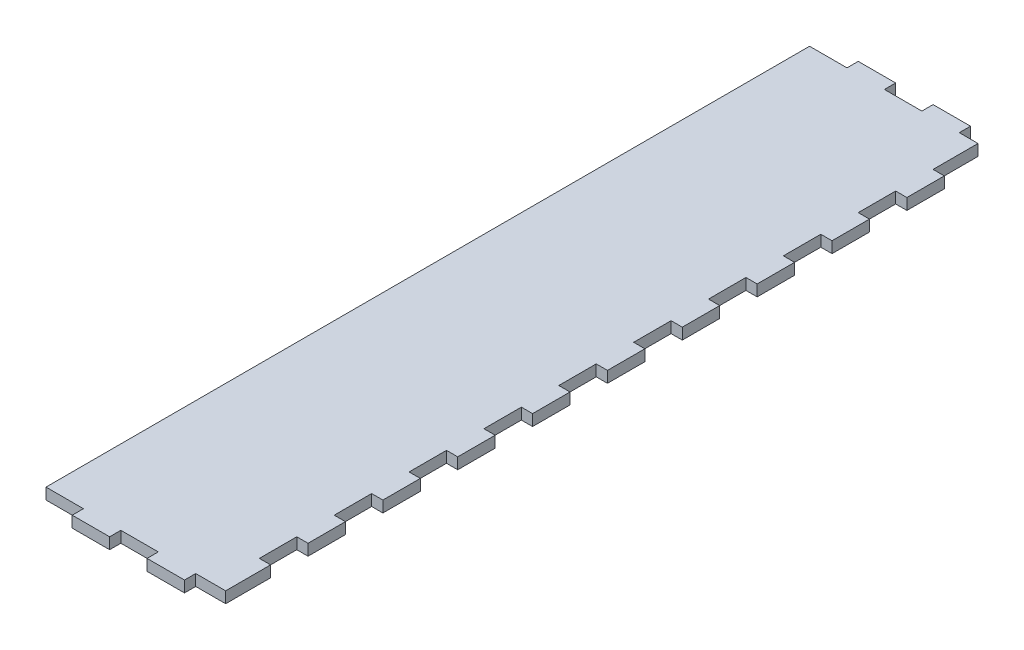
from build123d import *

# Parameters (mm, degrees)
SKETCH1_W           = 45
SKETCH1_H           = 204
BOSS_EXTRUDE1_DEPTH = 3
SKETCH2_W           = 10
SKETCH2_H           = 3
BOSS_EXTRUDE2_DEPTH = 3
LPATTERN1_COUNT     = 2
LPATTERN1_PITCH     = 20
SKETCH3_W           = 10
SKETCH3_H           = 3
BOSS_EXTRUDE3_DEPTH = 3
LPATTERN2_COUNT     = 2
LPATTERN2_PITCH     = 20
SKETCH4_W           = 12
SKETCH4_H           = 3
SKETCH4_W_2         = 10
BOSS_EXTRUDE4_DEPTH = 3


with BuildPart() as part:
    # Sketch1 → Boss-Extrude1 (new body)
    with BuildSketch(Plane(origin=(0, 0, 0), x_dir=(1, 0, 0), z_dir=(0, 1, 0))):
        with Locations((22.5, 102)):
            Rectangle(SKETCH1_W, SKETCH1_H)
    extrude(amount=BOSS_EXTRUDE1_DEPTH)

    # Sketch2 → Boss-Extrude2 (add)
    with BuildSketch(Plane.XY):
        with Locations((35, 1.5)):
            Rectangle(SKETCH2_W, SKETCH2_H)
    boss_extrude2 = extrude(amount=BOSS_EXTRUDE2_DEPTH)

    # LPattern1: Boss-Extrude2 ×2
    with Locations(*[(-i * LPATTERN1_PITCH, 0, 0) for i in range(1, LPATTERN1_COUNT)]):
        add(boss_extrude2)

    # Sketch3 → Boss-Extrude3 (add)
    with BuildSketch(Plane(origin=(0, 0, -204), x_dir=(-1, 0, 0), z_dir=(0, 0, -1))):
        with Locations((-35, 1.5)):
            Rectangle(SKETCH3_W, SKETCH3_H)
    boss_extrude3 = extrude(amount=BOSS_EXTRUDE3_DEPTH)

    # LPattern2: Boss-Extrude3 ×2
    with Locations(*[(-i * LPATTERN2_PITCH, 0, 0) for i in range(1, LPATTERN2_COUNT)]):
        add(boss_extrude3)

    # Sketch4 → Boss-Extrude4 (add)
    with BuildSketch(Plane(origin=(45, 0, 0), x_dir=(0, 0, -1), z_dir=(1, 0, 0))):
        with Locations((6, 1.5)):
            Rectangle(SKETCH4_W, SKETCH4_H)
        with Locations((27, 1.5)):
            Rectangle(SKETCH4_W_2, SKETCH4_H)
        with Locations((47, 1.5)):
            Rectangle(SKETCH4_W_2, SKETCH4_H)
        with Locations((67, 1.5)):
            Rectangle(SKETCH4_W_2, SKETCH4_H)
        with Locations((87, 1.5)):
            Rectangle(SKETCH4_W_2, SKETCH4_H)
        with Locations((107, 1.5)):
            Rectangle(SKETCH4_W_2, SKETCH4_H)
        with Locations((127, 1.5)):
            Rectangle(SKETCH4_W_2, SKETCH4_H)
        with Locations((147, 1.5)):
            Rectangle(SKETCH4_W_2, SKETCH4_H)
        with Locations((167, 1.5)):
            Rectangle(SKETCH4_W_2, SKETCH4_H)
        with Locations((187, 1.5)):
            Rectangle(SKETCH4_W_2, SKETCH4_H)
    extrude(amount=BOSS_EXTRUDE4_DEPTH)


solid = part.part
